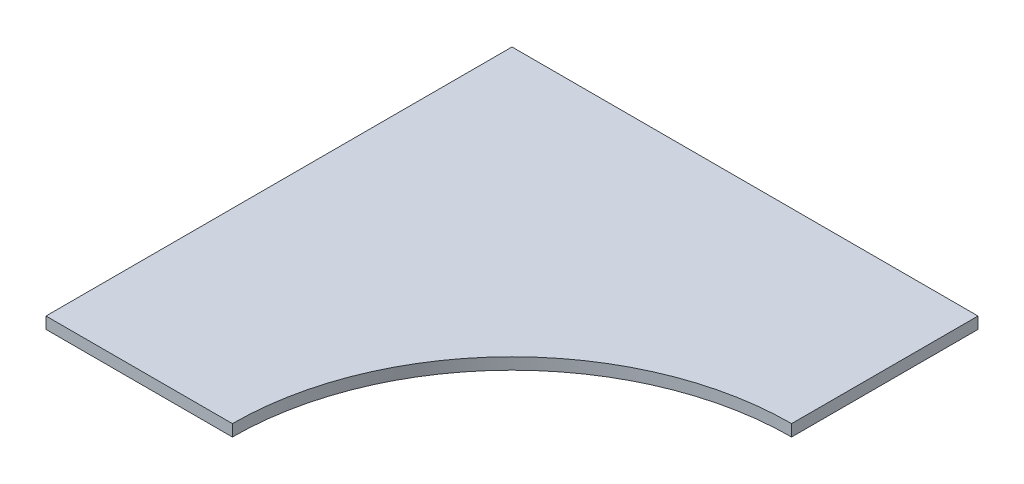
from build123d import *

# Parameters (mm, degrees)
BOSS_EXTRUDE1_DEPTH = 3.175


with BuildPart() as part:
    # Sketch1 → Boss-Extrude1 (new body)
    with BuildSketch(Plane(origin=(0, 0, 0), x_dir=(1, 0, 0), z_dir=(0, 1, 0))):
        with BuildLine():
            Line((0, 0), (0, 127))
            Line((0, 127), (127, 127))
            Line((127, 127), (127, 76.2))
            ThreePointArc((127, 76.2), (73.118463274, 53.881536726), (50.8, 0))
            Line((50.8, 0), (0, 0))
        make_face()
    extrude(amount=BOSS_EXTRUDE1_DEPTH)


solid = part.part
